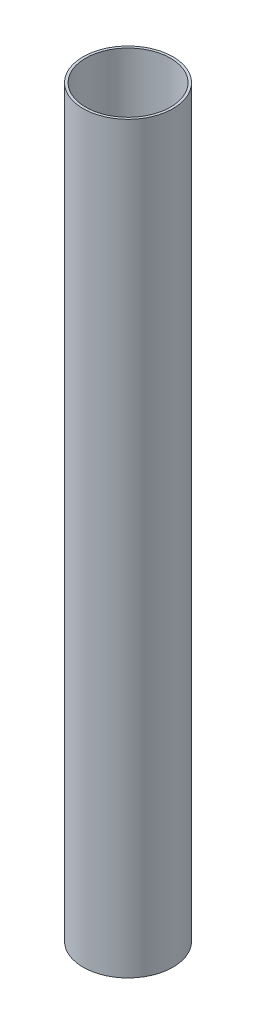
from build123d import *

# Parameters (mm, degrees)
SKETCH1_ONE_SIDE_W = 0.85
SKETCH1_ONE_SIDE_H = 254


with BuildPart() as part:
    # Sketch1 one side → Revolve2 (revolve)
    with BuildSketch(Plane.XY):
        with Locations((-14.925, 127)):
            Rectangle(SKETCH1_ONE_SIDE_W, SKETCH1_ONE_SIDE_H)
    revolve(axis=Axis((0, 0, 0), (0, 1, 0)))


solid = part.part
